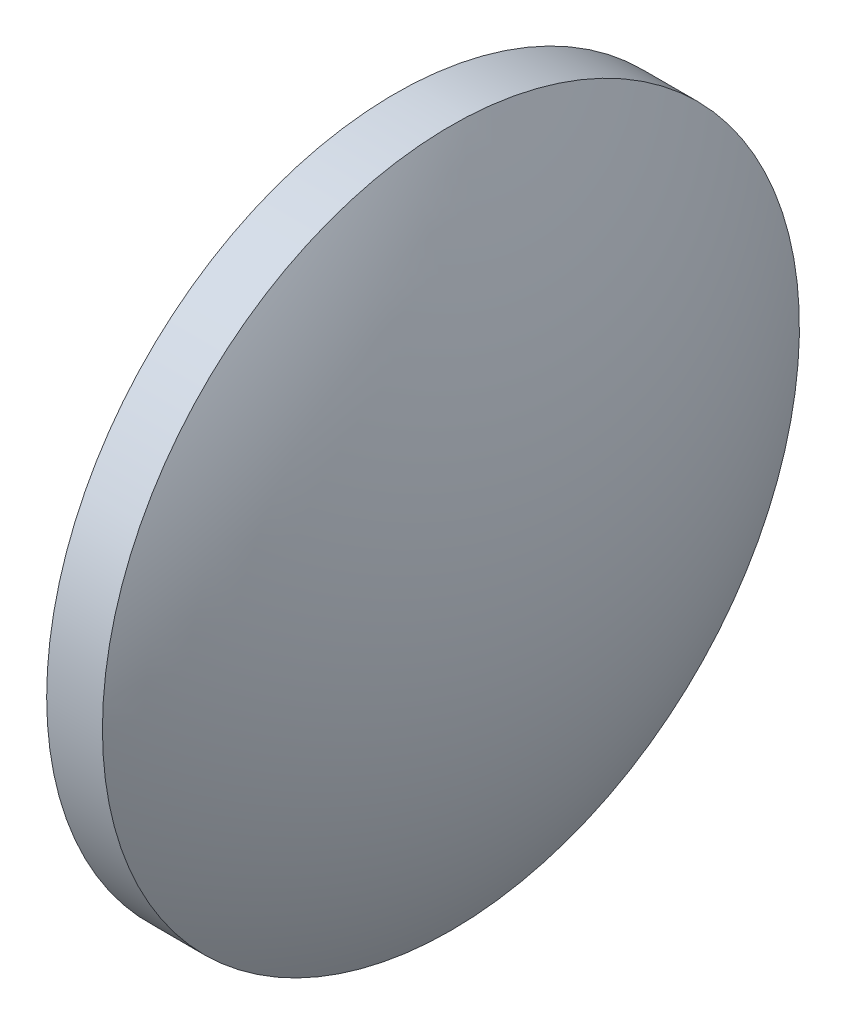
from build123d import *


with BuildPart() as part:
    # 草图1 → 旋转1 (revolve)
    with BuildSketch(Plane.XY, mode=Mode.PRIVATE) as revolve_1_sk:
        with BuildLine():
            Line((465.582132457, 58.167871727), (465.582132457, 65.667871727))
            Line((465.582132457, 65.667871727), (466.782132457, 65.667871727))
            ThreePointArc((466.782132457, 65.667871727), (468.273546235, 62.048915401), (468.782132457, 58.167871727))
            Line((468.782132457, 58.167871727), (465.582132457, 58.167871727))
        make_face()
    revolve(revolve_1_sk.sketch.rotate(Axis((462.741320326, 58.167871727, 0), (1, 0, 0)), 180), axis=Axis((462.741320326, 58.167871727, 0), (1, 0, 0)))  # turned: the seam where the file's is


solid = part.part
